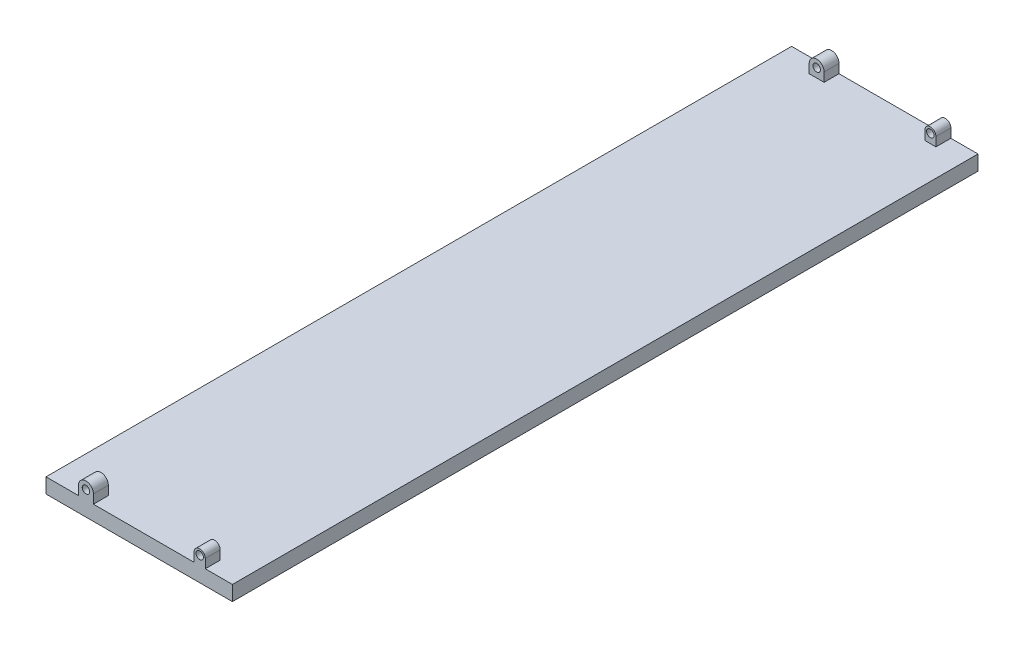
from build123d import *

# Parameters (mm, degrees)
SKETCH2_W                        = 250
SKETCH2_H                        = 20
BOSS_EXTRUDE1_DEPTH              = 1000
BOSS_EXTRUDE2_DEPTH              = 20
BOSS_EXTRUDE3_DEPTH              = 20
F_10_0MM_DOWEL_HOLE1_D           = 10
F_10_0MM_DOWEL_HOLE1_CSINK_D     = 10.05
F_10_0MM_DOWEL_HOLE1_CSINK_ANGLE = 90


with BuildPart() as part:
    # Sketch2 → Boss-Extrude1 (new body)
    with BuildSketch(Plane.XY):
        Rectangle(SKETCH2_W, SKETCH2_H)
    extrude(amount=-BOSS_EXTRUDE1_DEPTH)

    # Sketch3 → Boss-Extrude2 (add)
    with BuildSketch(Plane.XY):
        with BuildLine():
            Line((88.6, 10), (88.6, 22))
            ThreePointArc((88.6, 22), (81.1, 29.5), (73.6, 22))
            Line((73.6, 22), (73.6, 10))
            Line((73.6, 10), (88.6, 10))
        make_face()
    boss_extrude2 = extrude(amount=-BOSS_EXTRUDE2_DEPTH)

    # Sketch4 → Boss-Extrude3 (add)
    with BuildSketch(Plane.XY):
        with BuildLine():
            Line((-81.4, 10), (-81.4, 22))
            ThreePointArc((-81.4, 22), (-71.4, 32), (-61.4, 22))
            Line((-61.4, 22), (-61.4, 10))
            Line((-61.4, 10), (-81.4, 10))
        make_face()
    boss_extrude3 = extrude(amount=-BOSS_EXTRUDE3_DEPTH)

    # Ø10.0mm Dowel Hole1 (through all)
    with Locations(Plane.XY):
        with Locations((-71.4, 22), (81.1, 22)):
            f_10_0mm_dowel_hole1 = CounterSinkHole(F_10_0MM_DOWEL_HOLE1_D / 2, F_10_0MM_DOWEL_HOLE1_CSINK_D / 2, counter_sink_angle=F_10_0MM_DOWEL_HOLE1_CSINK_ANGLE)

    # Mirror1: Boss-Extrude2, Boss-Extrude3, Ø10.0mm Dowel Hole1 across plane
    add(boss_extrude2.mirror(Plane.XY.offset(-500)))
    add(boss_extrude3.mirror(Plane.XY.offset(-500)))
    add(f_10_0mm_dowel_hole1.mirror(Plane.XY.offset(-500)), mode=Mode.SUBTRACT)


solid = part.part
